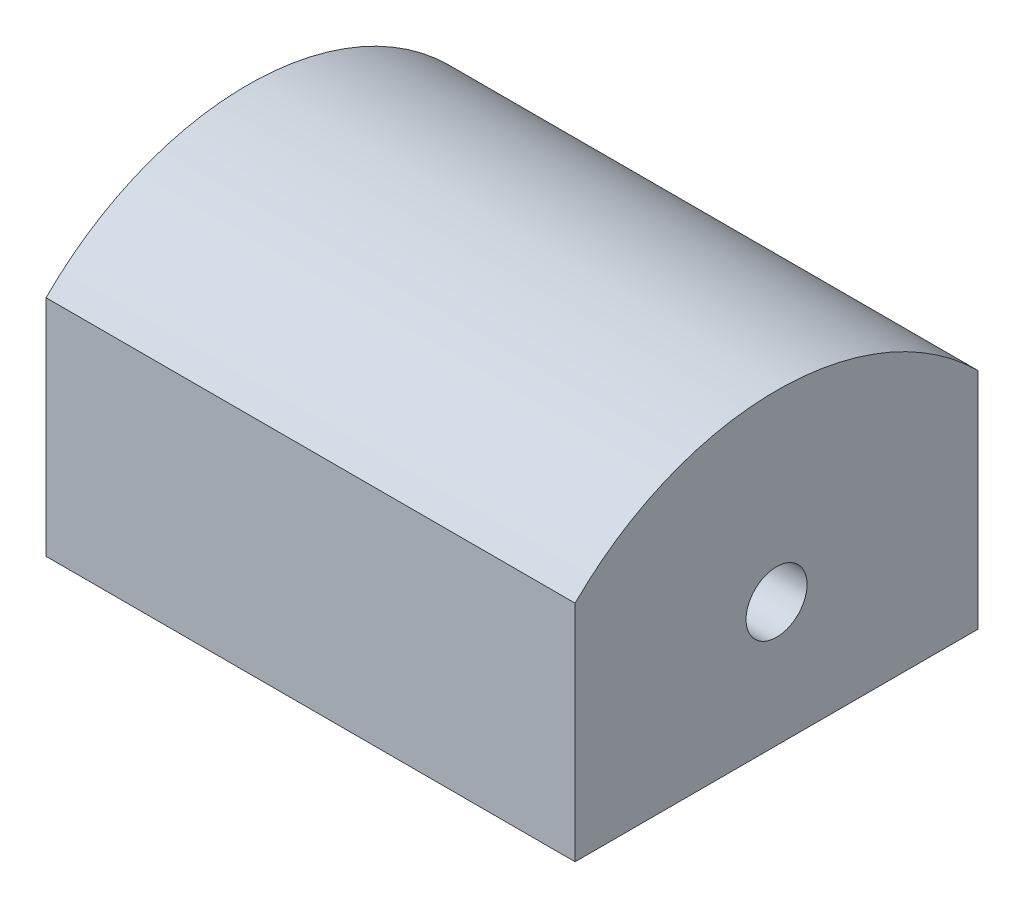
from build123d import *

# Parameters (mm, degrees)
BOSS_EXTRUDE1_DEPTH   = 13
F_1_5MM_DOWEL_SLOT1_D = 1.5


with BuildPart() as part:
    # Sketch1 → Boss-Extrude1 (new body)
    with BuildSketch(Plane(origin=(0, 0, 0), x_dir=(0, 0, -1), z_dir=(1, 0, 0))):
        with BuildLine():
            Line((0, 0), (-9.899494937, 0))
            Line((-9.899494937, 0), (-9.899494937, 5.503823677))
            ThreePointArc((-9.899494937, 5.503823677), (-4.949747468, 7.554076209), (0, 5.503823677))
            Line((0, 5.503823677), (0, 0))
        make_face()
    extrude(amount=BOSS_EXTRUDE1_DEPTH)

    # Ø1.5mm Dowel Slot1 (through all)
    with Locations(Plane(origin=(13, 0, 0), x_dir=(0, 0, -1), z_dir=(1, 0, 0))):
        with Locations((-4.949747468, 3.054076209)):
            Hole(F_1_5MM_DOWEL_SLOT1_D / 2)


solid = part.part
